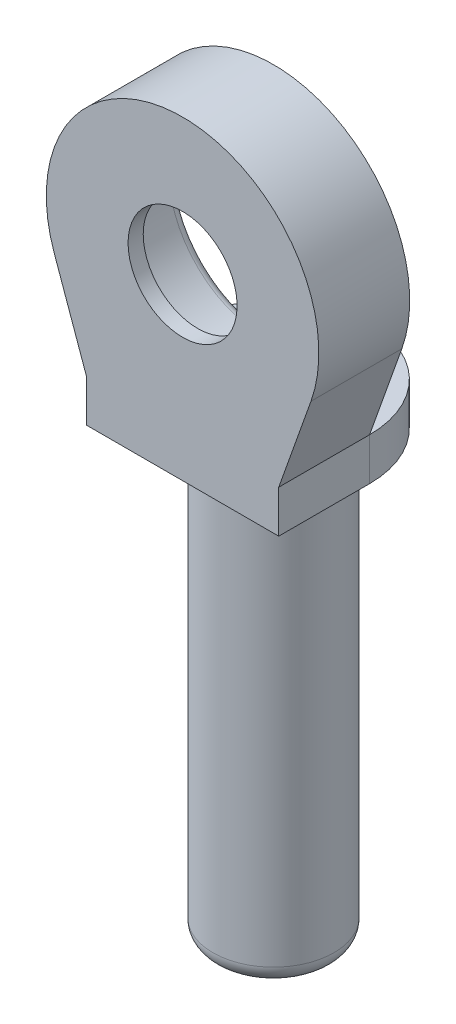
from build123d import *

# Parameters (mm, degrees)
SKETCH_1_R               = 2
EXTRUDE_1_DEPTH          = 16
EXTRUDE_2_DEPTH          = 3
SKETCH_4_R               = 3.15
CUT_EXTRUDE_6_DEPTH      = 2.5
FILLET_3_R               = 0.6
SKETCH_7_R               = 3.175
EXTRUDE_3_DEPTH          = 1.4
CUT_EXTRUDE_9_DEPTH      = 1
CUT_EXTRUDE_9_DEPTH_BACK = 26
FILLET_6_R               = 1
EXTRUDE_5_DEPTH          = 3
FILLET_7_R               = 0.3
CUT_EXTRUDE_10_REACH     = 2.675
SKETCH_13_R              = 1.8
CUT_EXTRUDE_11_REACH     = 18
SKETCH_14_W              = 2.079062288
SKETCH_14_H              = 0.49177122


with BuildPart() as part:
    # 草图1 → 凸台-拉伸1 (new body)
    with BuildSketch(Plane(origin=(0, 0, 0), x_dir=(1, 0, 0), z_dir=(0, 1, 0))):
        Circle(SKETCH_1_R)
    extrude(amount=EXTRUDE_1_DEPTH)

    # 圆角3
    fillet_3_edges = [part.edges().sort_by_distance(p)[0] for p in [
        (-2, 0, 0),
    ]]
    fillet(fillet_3_edges, radius=FILLET_3_R)

    # 草图7 → 凸台-拉伸3 (add)
    with BuildSketch(Plane(origin=(0, 16, 0), x_dir=(1, 0, 0), z_dir=(0, 1, 0))):
        Circle(SKETCH_7_R)
    extrude(amount=-EXTRUDE_3_DEPTH)

    # 草图10 → 切除-拉伸9 (cut, two sides)
    with BuildSketch(Plane.XZ) as cut_extrude_9_sk:
        with BuildLine():
            Line((-1.307669683, 0.5), (1.307669683, 0.5))
            ThreePointArc((1.307669683, 0.5), (0, -1.4), (-1.307669683, 0.5))
        make_face()
    extrude(amount=CUT_EXTRUDE_9_DEPTH, mode=Mode.SUBTRACT)
    extrude(cut_extrude_9_sk.sketch, amount=-CUT_EXTRUDE_9_DEPTH_BACK, mode=Mode.SUBTRACT)

    # 圆角6
    fillet_6_edges = [part.edges().sort_by_distance(p)[0] for p in [
        (0, 16, -1.4),
    ]]
    fillet(fillet_6_edges, radius=FILLET_6_R)



with BuildPart() as body_2:
    # 草图2 → 凸台-拉伸2 (new body)
    with BuildSketch(Plane.XY):
        with BuildLine():
            ThreePointArc((4.245738578, 21.991208882), (-3.671541908, 23.101880092), (0, 16))
            ThreePointArc((0, 16), (3.671541908, 17.898119908), (4.245738578, 21.991208882))
        make_face()
    extrude(amount=EXTRUDE_2_DEPTH)

    # 草图4 → 切除-拉伸6 (cut)
    with BuildSketch(Plane(origin=(0, 0, 0), x_dir=(-1, 0, 0), z_dir=(0, 0, -1))):
        with Locations((0, 20.5)):
            Circle(SKETCH_4_R)
    extrude(amount=-CUT_EXTRUDE_6_DEPTH, mode=Mode.SUBTRACT)


with BuildPart() as part_1:
    add(part.part)

    add(body_2.part)  # 凸台-拉伸5 merges body 2
    # 草图12 → 凸台-拉伸5 (add)
    with BuildSketch(Plane.XY.offset(3)):
        with BuildLine():
            Line((-3.175, 16), (-4.239526881, 18.991221744))
            ThreePointArc((-4.239526881, 18.991221744), (0, 16), (4.239526881, 18.991221744))
            Line((4.239526881, 18.991221744), (3.175, 16))
            Line((3.175, 16), (3.175, 14.6))
            Line((3.175, 14.6), (-3.175, 14.6))
            Line((-3.175, 14.6), (-3.175, 16))
        make_face()
    extrude(amount=-EXTRUDE_5_DEPTH)

    # 圆角7
    fillet_7_edges = [part_1.edges().sort_by_distance(p)[0] for p in [
        (3.15, 20.5, 0),
    ]]
    fillet(fillet_7_edges, radius=FILLET_7_R)

    # 草图13 → 切除-拉伸10 (cut, up to next)
    with BuildSketch(Plane(origin=(0, 0, 2.5), x_dir=(-1, 0, 0), z_dir=(0, 0, -1)), mode=Mode.PRIVATE) as cut_extrude_10_sk1:
        with Locations((0, 20.5)):
            Circle(SKETCH_13_R)
    cut_extrude_10_tool1 = extrude(cut_extrude_10_sk1.sketch, amount=-CUT_EXTRUDE_10_REACH, mode=Mode.PRIVATE) & part_1.part
    add(cut_extrude_10_tool1.solids().sort_by_distance((0, 20.5, 2.5))[0], mode=Mode.SUBTRACT)

    # 草图14 → 切除-拉伸11 (cut, up to next)
    with BuildSketch(Plane(origin=(0, 16, 0), x_dir=(1, 0, 0), z_dir=(0, 1, 0)), mode=Mode.PRIVATE) as cut_extrude_11_sk1:
        with Locations((0, -3.24588561)):
            Rectangle(SKETCH_14_W, SKETCH_14_H)
    cut_extrude_11_tool1 = extrude(cut_extrude_11_sk1.sketch, amount=-CUT_EXTRUDE_11_REACH, mode=Mode.PRIVATE) & part_1.part
    add(cut_extrude_11_tool1.solids().sort_by_distance((0, 16, 3.245886))[0], mode=Mode.SUBTRACT)


solid = part_1.part
